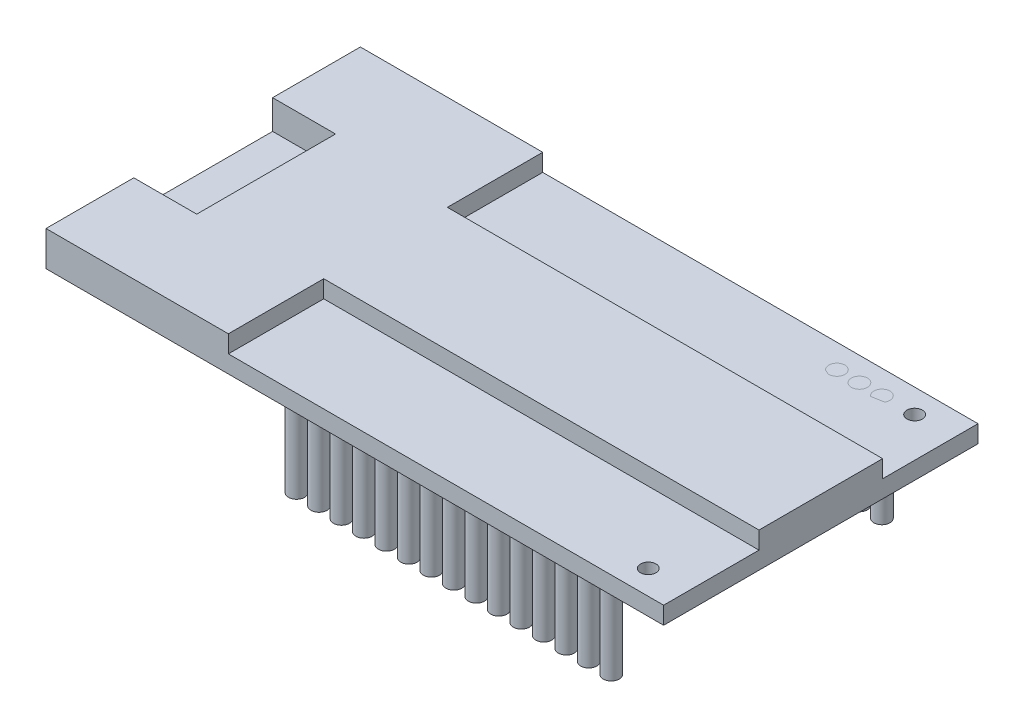
from build123d import *

# Parameters (mm, degrees)
SKETCH1_W              = 54.95
SKETCH1_H              = 27.97
BOSS_EXTRUDE1_DEPTH    = 3.1
SKETCH2_R              = 0.690254267
SKETCH2_R_2            = 0.688211373
CUT_EXTRUDE1_DEPTH     = 3.1
SKETCH3_W              = 38.725
SKETCH3_H              = 8.485
CUT_EXTRUDE2_DEPTH     = 1.55
SKETCH4_R              = 0.717372299
BOSS_EXTRUDE2_DEPTH    = 9.44
BOSS_EXTRUDE2_2_DEPTH  = 9.44
BOSS_EXTRUDE2_3_DEPTH  = 9.44
BOSS_EXTRUDE2_4_DEPTH  = 9.44
BOSS_EXTRUDE2_5_DEPTH  = 9.44
BOSS_EXTRUDE2_6_DEPTH  = 9.44
BOSS_EXTRUDE2_7_DEPTH  = 9.44
BOSS_EXTRUDE2_8_DEPTH  = 9.44
BOSS_EXTRUDE2_9_DEPTH  = 9.44
BOSS_EXTRUDE2_10_DEPTH = 9.44
BOSS_EXTRUDE2_11_DEPTH = 9.44
BOSS_EXTRUDE2_12_DEPTH = 9.44
BOSS_EXTRUDE2_13_DEPTH = 9.44
BOSS_EXTRUDE2_14_DEPTH = 9.44
BOSS_EXTRUDE2_15_DEPTH = 9.44
BOSS_EXTRUDE2_16_DEPTH = 9.44
BOSS_EXTRUDE2_17_DEPTH = 9.44
BOSS_EXTRUDE2_18_DEPTH = 9.44
BOSS_EXTRUDE2_19_DEPTH = 9.44
BOSS_EXTRUDE2_20_DEPTH = 9.44
BOSS_EXTRUDE2_21_DEPTH = 9.44
BOSS_EXTRUDE2_22_DEPTH = 9.44
BOSS_EXTRUDE2_23_DEPTH = 9.44
BOSS_EXTRUDE2_24_DEPTH = 9.44
BOSS_EXTRUDE2_25_DEPTH = 9.44
BOSS_EXTRUDE2_26_DEPTH = 9.44
BOSS_EXTRUDE2_27_DEPTH = 9.44
BOSS_EXTRUDE2_28_DEPTH = 9.44
BOSS_EXTRUDE2_29_DEPTH = 9.44
BOSS_EXTRUDE2_30_DEPTH = 9.44
SKETCH5_W              = 5.6
SKETCH5_H              = 8.35
CUT_EXTRUDE3_DEPTH     = 2.6
CHAMFER1_SIZE          = 2
SKETCH6_W              = 2
SKETCH6_H              = 2.6
CUT_EXTRUDE5_DEPTH     = 5.6


with BuildPart() as part:
    # Sketch1 → Boss-Extrude1 (new body)
    with BuildSketch(Plane(origin=(0, 0, 0), x_dir=(1, 0, 0), z_dir=(0, 1, 0))):
        Rectangle(SKETCH1_W, SKETCH1_H)
    extrude(amount=BOSS_EXTRUDE1_DEPTH)

    # Sketch2 → Cut-Extrude1 (cut)
    with BuildSketch(Plane(origin=(0, 3.1, 0), x_dir=(1, 0, 0), z_dir=(0, 1, 0))):
        with Locations((23.954612537, 11.871833626)):
            Circle(SKETCH2_R)
        with Locations((23.954612537, -11.829726089)):
            Circle(SKETCH2_R_2)
    extrude(amount=-CUT_EXTRUDE1_DEPTH, mode=Mode.SUBTRACT)

    # Sketch3 → Cut-Extrude2 (cut)
    with BuildSketch(Plane(origin=(0, 3.1, 0), x_dir=(1, 0, 0), z_dir=(0, 1, 0))):
        with Locations((8.1125, 9.7425)):
            Rectangle(SKETCH3_W, SKETCH3_H)
        with Locations((8.1125, -9.7425)):
            Rectangle(SKETCH3_W, SKETCH3_H)
    extrude(amount=-CUT_EXTRUDE2_DEPTH, mode=Mode.SUBTRACT)

    # Sketch5 → Cut-Extrude3 (cut)
    with BuildSketch(Plane(origin=(0, 3.1, 0), x_dir=(1, 0, 0), z_dir=(0, 1, 0))):
        with Locations((-24.675, 0)):
            Rectangle(SKETCH5_W, SKETCH5_H)
    extrude(amount=-CUT_EXTRUDE3_DEPTH, mode=Mode.SUBTRACT)

    # Chamfer1
    chamfer1_edges = [part.edges().sort_by_distance(p)[0] for p in [
        (-24.675, 3.1, 4.175),
        (-24.675, 3.1, -4.175),
    ]]
    chamfer(chamfer1_edges, length=CHAMFER1_SIZE)

    # Sketch6 → Cut-Extrude5 (cut)
    with BuildSketch(Plane.ZY.offset(27.475)):
        with Locations((-5.175, 1.8)):
            Rectangle(SKETCH6_W, SKETCH6_H)
        with Locations((5.175, 1.8)):
            Rectangle(SKETCH6_W, SKETCH6_H)
    extrude(amount=-CUT_EXTRUDE5_DEPTH, mode=Mode.SUBTRACT)


with BuildPart() as body_2:
    # Sketch4 → Boss-Extrude2 (new body)
    with BuildSketch(Plane(origin=(0, 1.55, 0), x_dir=(1, 0, 0), z_dir=(0, 1, 0))):
        with Locations((21.042209533, 11.865840209)):
            Circle(SKETCH4_R)
    extrude(amount=-BOSS_EXTRUDE2_DEPTH)


with BuildPart() as body_3:
    # Sketch4 → Boss-Extrude2 2 (new body)
    with BuildSketch(Plane(origin=(0, 1.55, 0), x_dir=(1, 0, 0), z_dir=(0, 1, 0))):
        with Locations((21.042209533, -12.21096759)):
            Circle(SKETCH4_R)
    extrude(amount=-BOSS_EXTRUDE2_2_DEPTH)


with BuildPart() as body_4:
    # Sketch4 → Boss-Extrude2 3 (new body)
    with BuildSketch(Plane(origin=(0, 1.55, 0), x_dir=(1, 0, 0), z_dir=(0, 1, 0))):
        with Locations((19.042209533, -12.21096759)):
            Circle(SKETCH4_R)
    extrude(amount=-BOSS_EXTRUDE2_3_DEPTH)


with BuildPart() as body_5:
    # Sketch4 → Boss-Extrude2 4 (new body)
    with BuildSketch(Plane(origin=(0, 1.55, 0), x_dir=(1, 0, 0), z_dir=(0, 1, 0))):
        with Locations((17.042209533, -12.21096759)):
            Circle(SKETCH4_R)
    extrude(amount=-BOSS_EXTRUDE2_4_DEPTH)


with BuildPart() as body_6:
    # Sketch4 → Boss-Extrude2 5 (new body)
    with BuildSketch(Plane(origin=(0, 1.55, 0), x_dir=(1, 0, 0), z_dir=(0, 1, 0))):
        with Locations((15.042209533, -12.21096759)):
            Circle(SKETCH4_R)
    extrude(amount=-BOSS_EXTRUDE2_5_DEPTH)


with BuildPart() as body_7:
    # Sketch4 → Boss-Extrude2 6 (new body)
    with BuildSketch(Plane(origin=(0, 1.55, 0), x_dir=(1, 0, 0), z_dir=(0, 1, 0))):
        with Locations((13.042209533, -12.21096759)):
            Circle(SKETCH4_R)
    extrude(amount=-BOSS_EXTRUDE2_6_DEPTH)


with BuildPart() as body_8:
    # Sketch4 → Boss-Extrude2 7 (new body)
    with BuildSketch(Plane(origin=(0, 1.55, 0), x_dir=(1, 0, 0), z_dir=(0, 1, 0))):
        with Locations((11.042209533, -12.21096759)):
            Circle(SKETCH4_R)
    extrude(amount=-BOSS_EXTRUDE2_7_DEPTH)


with BuildPart() as body_9:
    # Sketch4 → Boss-Extrude2 8 (new body)
    with BuildSketch(Plane(origin=(0, 1.55, 0), x_dir=(1, 0, 0), z_dir=(0, 1, 0))):
        with Locations((9.042209533, -12.21096759)):
            Circle(SKETCH4_R)
    extrude(amount=-BOSS_EXTRUDE2_8_DEPTH)


with BuildPart() as body_10:
    # Sketch4 → Boss-Extrude2 9 (new body)
    with BuildSketch(Plane(origin=(0, 1.55, 0), x_dir=(1, 0, 0), z_dir=(0, 1, 0))):
        with Locations((7.042209533, -12.21096759)):
            Circle(SKETCH4_R)
    extrude(amount=-BOSS_EXTRUDE2_9_DEPTH)


with BuildPart() as body_11:
    # Sketch4 → Boss-Extrude2 10 (new body)
    with BuildSketch(Plane(origin=(0, 1.55, 0), x_dir=(1, 0, 0), z_dir=(0, 1, 0))):
        with Locations((5.042209533, -12.21096759)):
            Circle(SKETCH4_R)
    extrude(amount=-BOSS_EXTRUDE2_10_DEPTH)


with BuildPart() as body_12:
    # Sketch4 → Boss-Extrude2 11 (new body)
    with BuildSketch(Plane(origin=(0, 1.55, 0), x_dir=(1, 0, 0), z_dir=(0, 1, 0))):
        with Locations((3.042209533, -12.21096759)):
            Circle(SKETCH4_R)
    extrude(amount=-BOSS_EXTRUDE2_11_DEPTH)


with BuildPart() as body_13:
    # Sketch4 → Boss-Extrude2 12 (new body)
    with BuildSketch(Plane(origin=(0, 1.55, 0), x_dir=(1, 0, 0), z_dir=(0, 1, 0))):
        with Locations((1.042209533, -12.21096759)):
            Circle(SKETCH4_R)
    extrude(amount=-BOSS_EXTRUDE2_12_DEPTH)


with BuildPart() as body_14:
    # Sketch4 → Boss-Extrude2 13 (new body)
    with BuildSketch(Plane(origin=(0, 1.55, 0), x_dir=(1, 0, 0), z_dir=(0, 1, 0))):
        with Locations((-0.957790467, -12.21096759)):
            Circle(SKETCH4_R)
    extrude(amount=-BOSS_EXTRUDE2_13_DEPTH)


with BuildPart() as body_15:
    # Sketch4 → Boss-Extrude2 14 (new body)
    with BuildSketch(Plane(origin=(0, 1.55, 0), x_dir=(1, 0, 0), z_dir=(0, 1, 0))):
        with Locations((-2.957790467, -12.21096759)):
            Circle(SKETCH4_R)
    extrude(amount=-BOSS_EXTRUDE2_14_DEPTH)


with BuildPart() as body_16:
    # Sketch4 → Boss-Extrude2 15 (new body)
    with BuildSketch(Plane(origin=(0, 1.55, 0), x_dir=(1, 0, 0), z_dir=(0, 1, 0))):
        with Locations((-4.957790467, -12.21096759)):
            Circle(SKETCH4_R)
    extrude(amount=-BOSS_EXTRUDE2_15_DEPTH)


with BuildPart() as body_17:
    # Sketch4 → Boss-Extrude2 16 (new body)
    with BuildSketch(Plane(origin=(0, 1.55, 0), x_dir=(1, 0, 0), z_dir=(0, 1, 0))):
        with Locations((-6.957790467, -12.21096759)):
            Circle(SKETCH4_R)
    extrude(amount=-BOSS_EXTRUDE2_16_DEPTH)


with BuildPart() as body_18:
    # Sketch4 → Boss-Extrude2 17 (new body)
    with BuildSketch(Plane(origin=(0, 1.55, 0), x_dir=(1, 0, 0), z_dir=(0, 1, 0))):
        with Locations((19.042209533, 11.865840209)):
            Circle(SKETCH4_R)
    extrude(amount=-BOSS_EXTRUDE2_17_DEPTH)


with BuildPart() as body_19:
    # Sketch4 → Boss-Extrude2 18 (new body)
    with BuildSketch(Plane(origin=(0, 1.55, 0), x_dir=(1, 0, 0), z_dir=(0, 1, 0))):
        with Locations((17.042209533, 11.865840209)):
            Circle(SKETCH4_R)
    extrude(amount=-BOSS_EXTRUDE2_18_DEPTH)


with BuildPart() as body_20:
    # Sketch4 → Boss-Extrude2 19 (new body)
    with BuildSketch(Plane(origin=(0, 1.55, 0), x_dir=(1, 0, 0), z_dir=(0, 1, 0))):
        with Locations((15.042209533, 11.865840209)):
            Circle(SKETCH4_R)
    extrude(amount=-BOSS_EXTRUDE2_19_DEPTH)


with BuildPart() as body_21:
    # Sketch4 → Boss-Extrude2 20 (new body)
    with BuildSketch(Plane(origin=(0, 1.55, 0), x_dir=(1, 0, 0), z_dir=(0, 1, 0))):
        with Locations((13.042209533, 11.865840209)):
            Circle(SKETCH4_R)
    extrude(amount=-BOSS_EXTRUDE2_20_DEPTH)


with BuildPart() as body_22:
    # Sketch4 → Boss-Extrude2 21 (new body)
    with BuildSketch(Plane(origin=(0, 1.55, 0), x_dir=(1, 0, 0), z_dir=(0, 1, 0))):
        with Locations((11.042209533, 11.865840209)):
            Circle(SKETCH4_R)
    extrude(amount=-BOSS_EXTRUDE2_21_DEPTH)


with BuildPart() as body_23:
    # Sketch4 → Boss-Extrude2 22 (new body)
    with BuildSketch(Plane(origin=(0, 1.55, 0), x_dir=(1, 0, 0), z_dir=(0, 1, 0))):
        with Locations((9.042209533, 11.865840209)):
            Circle(SKETCH4_R)
    extrude(amount=-BOSS_EXTRUDE2_22_DEPTH)


with BuildPart() as body_24:
    # Sketch4 → Boss-Extrude2 23 (new body)
    with BuildSketch(Plane(origin=(0, 1.55, 0), x_dir=(1, 0, 0), z_dir=(0, 1, 0))):
        with Locations((7.042209533, 11.865840209)):
            Circle(SKETCH4_R)
    extrude(amount=-BOSS_EXTRUDE2_23_DEPTH)


with BuildPart() as body_25:
    # Sketch4 → Boss-Extrude2 24 (new body)
    with BuildSketch(Plane(origin=(0, 1.55, 0), x_dir=(1, 0, 0), z_dir=(0, 1, 0))):
        with Locations((5.042209533, 11.865840209)):
            Circle(SKETCH4_R)
    extrude(amount=-BOSS_EXTRUDE2_24_DEPTH)


with BuildPart() as body_26:
    # Sketch4 → Boss-Extrude2 25 (new body)
    with BuildSketch(Plane(origin=(0, 1.55, 0), x_dir=(1, 0, 0), z_dir=(0, 1, 0))):
        with Locations((3.042209533, 11.865840209)):
            Circle(SKETCH4_R)
    extrude(amount=-BOSS_EXTRUDE2_25_DEPTH)


with BuildPart() as body_27:
    # Sketch4 → Boss-Extrude2 26 (new body)
    with BuildSketch(Plane(origin=(0, 1.55, 0), x_dir=(1, 0, 0), z_dir=(0, 1, 0))):
        with Locations((1.042209533, 11.865840209)):
            Circle(SKETCH4_R)
    extrude(amount=-BOSS_EXTRUDE2_26_DEPTH)


with BuildPart() as body_28:
    # Sketch4 → Boss-Extrude2 27 (new body)
    with BuildSketch(Plane(origin=(0, 1.55, 0), x_dir=(1, 0, 0), z_dir=(0, 1, 0))):
        with Locations((-0.957790467, 11.865840209)):
            Circle(SKETCH4_R)
    extrude(amount=-BOSS_EXTRUDE2_27_DEPTH)


with BuildPart() as body_29:
    # Sketch4 → Boss-Extrude2 28 (new body)
    with BuildSketch(Plane(origin=(0, 1.55, 0), x_dir=(1, 0, 0), z_dir=(0, 1, 0))):
        with Locations((-2.957790467, 11.865840209)):
            Circle(SKETCH4_R)
    extrude(amount=-BOSS_EXTRUDE2_28_DEPTH)


with BuildPart() as body_30:
    # Sketch4 → Boss-Extrude2 29 (new body)
    with BuildSketch(Plane(origin=(0, 1.55, 0), x_dir=(1, 0, 0), z_dir=(0, 1, 0))):
        with Locations((-4.957790467, 11.865840209)):
            Circle(SKETCH4_R)
    extrude(amount=-BOSS_EXTRUDE2_29_DEPTH)


with BuildPart() as body_31:
    # Sketch4 → Boss-Extrude2 30 (new body)
    with BuildSketch(Plane(origin=(0, 1.55, 0), x_dir=(1, 0, 0), z_dir=(0, 1, 0))):
        with Locations((-6.957790467, 11.865840209)):
            Circle(SKETCH4_R)
    extrude(amount=-BOSS_EXTRUDE2_30_DEPTH)


solid = Compound([part.part, body_2.part, body_3.part, body_4.part, body_5.part, body_6.part, body_7.part, body_8.part, body_9.part, body_10.part, body_11.part, body_12.part, body_13.part, body_14.part, body_15.part, body_16.part, body_17.part, body_18.part, body_19.part, body_20.part, body_21.part, body_22.part, body_23.part, body_24.part, body_25.part, body_26.part, body_27.part, body_28.part, body_29.part, body_30.part, body_31.part])
